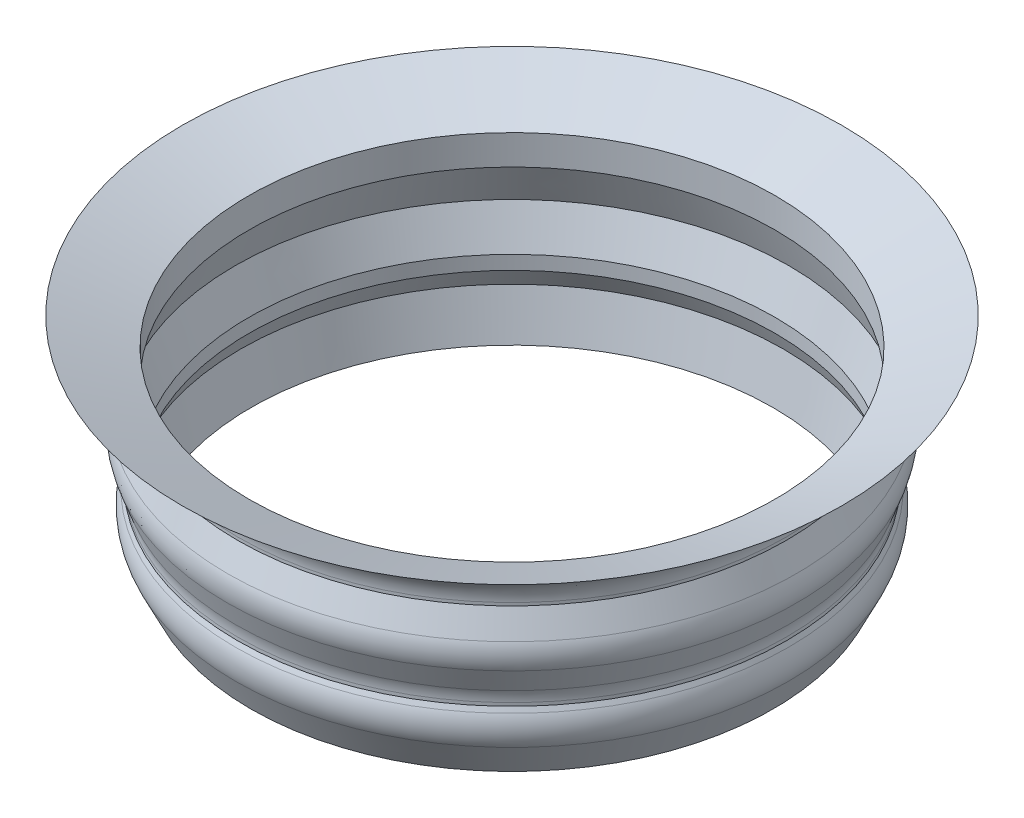
from build123d import *

# Parameters (mm, degrees)
FILLET1_R = 7.62


with BuildPart() as part:
    # Sketch2 → Revolve1 (revolve)
    with BuildSketch(Plane.XY):
        Polygon((-58.2676, 43.2769703), (-58.2676, 40.2035703), (-60.12897926, 36.239383837), (-57.831323448, 26.163828165), (-62.828989293, 36.465258256), (-60.8076, 40.770218692), (-60.8076, 42.829099769), (-64.137873862, 51.978952006), (-60.8076, 60.025592649), (-60.8076, 64.821818572), (-73.025, 72.733281474), (-58.2676, 66.631684467), (-58.2676, 60.025592649), (-61.3156, 51.651281474), align=None)
    revolve(axis=Axis((0, 0, 0), (0, 1, 0)))

    # Fillet1
    fillet1_edges = [part.edges().sort_by_distance(p)[0] for p in [
        (64.137873862, 51.978952006, 0),
        (60.8076, 42.829099769, 0),
        (62.828989293, 36.465258256, 0),
        (60.8076, 64.821818572, 0),
    ]]
    fillet(fillet1_edges, radius=FILLET1_R)


solid = part.part
